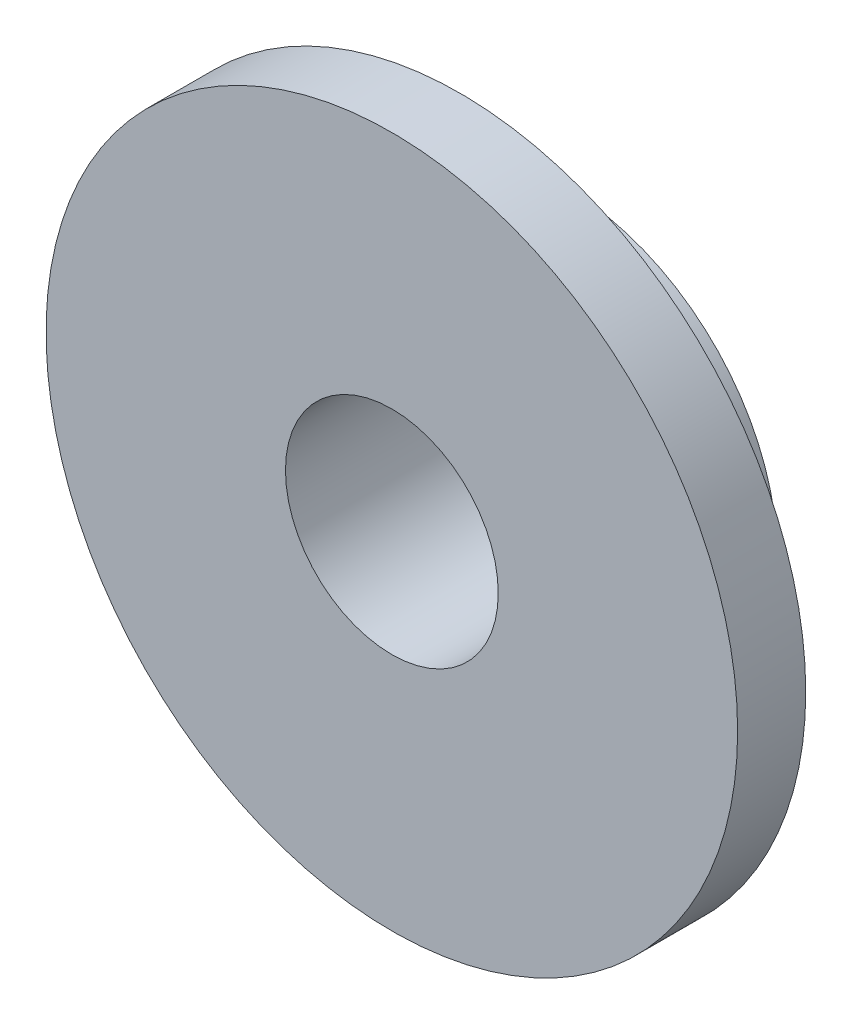
from build123d import *

# Parameters (mm, degrees)
SKETCH1_R           = 20.6375
SKETCH1_R_2         = 6.35
BOSS_EXTRUDE1_DEPTH = 4.064
SKETCH2_R           = 12.7
SKETCH2_R_2         = 6.35
BOSS_EXTRUDE2_DEPTH = 6.223


with BuildPart() as part:
    # Sketch1 → Boss-Extrude1 (new body)
    with BuildSketch(Plane.XY):
        Circle(SKETCH1_R)
        Circle(SKETCH1_R_2, mode=Mode.SUBTRACT)
    extrude(amount=BOSS_EXTRUDE1_DEPTH)

    # Sketch2 → Boss-Extrude2 (add)
    with BuildSketch(Plane(origin=(0, 0, 0), x_dir=(-1, 0, 0), z_dir=(0, 0, -1))):
        Circle(SKETCH2_R)
        Circle(SKETCH2_R_2, mode=Mode.SUBTRACT)
    extrude(amount=BOSS_EXTRUDE2_DEPTH)


solid = part.part
